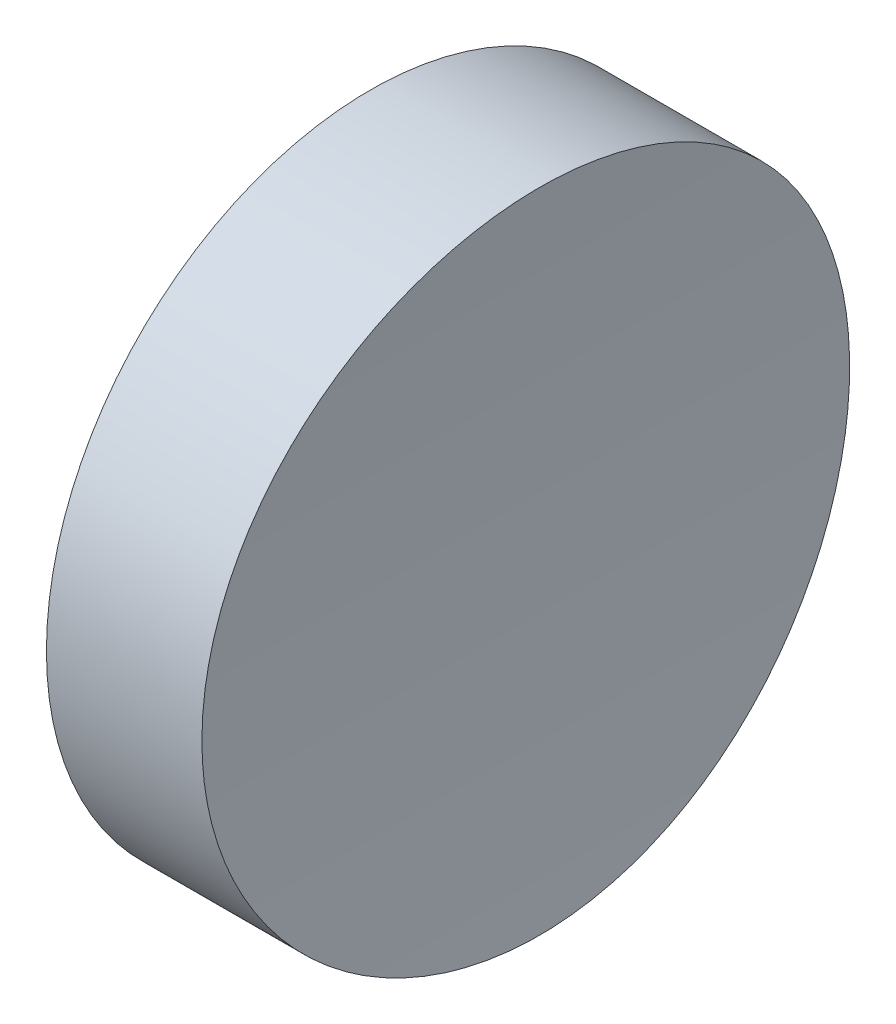
from build123d import *

# Parameters (mm, degrees)
SKETCH_1_R               = 12.5
EXTRUDE_1_DEPTH          = 10
SKETCH_2_R               = 150
CUT_EXTRUDE_1_DEPTH      = 13.5
CUT_EXTRUDE_1_DEPTH_BACK = 13.5


with BuildPart() as part:
    # 草图1 → 凸台-拉伸1 (new body)
    with BuildSketch(Plane(origin=(0, 0, 0), x_dir=(0, 0, -1), z_dir=(1, 0, 0))):
        Circle(SKETCH_1_R)
    extrude(amount=EXTRUDE_1_DEPTH)

    # 草图2 → 切除-拉伸1 (cut, two sides)
    with BuildSketch(Plane.XY) as cut_extrude_1_sk:
        with Locations((156, 0)):
            Circle(SKETCH_2_R)
    extrude(amount=CUT_EXTRUDE_1_DEPTH, mode=Mode.SUBTRACT)
    extrude(cut_extrude_1_sk.sketch, amount=-CUT_EXTRUDE_1_DEPTH_BACK, mode=Mode.SUBTRACT)


solid = part.part
